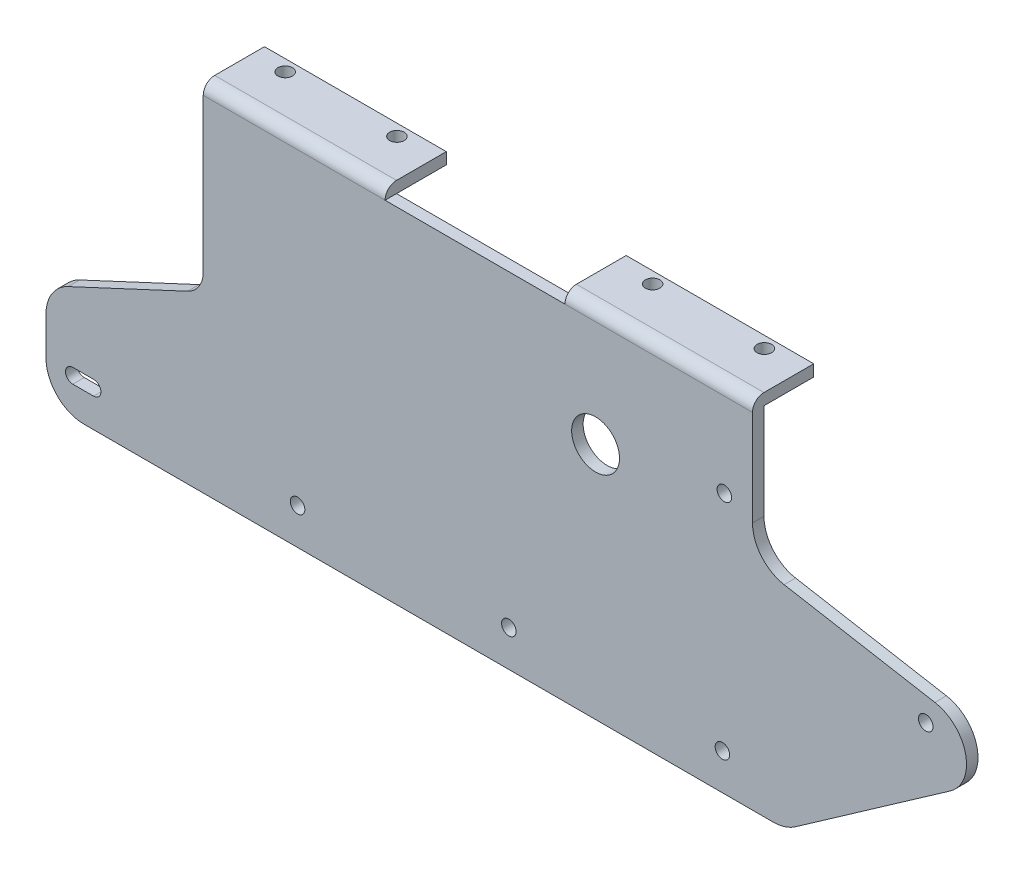
from build123d import *

# Parameters (mm, degrees)
BOSS_EXTRUDE1_DEPTH = 3
SKETCH2_R           = 1.9
SKETCH2_R_2         = 6.25
CUT_EXTRUDE1_DEPTH  = 4
BOSS_EXTRUDE2_DEPTH = 143.5
SKETCH4_W           = 47
SKETCH4_H           = 16
CUT_EXTRUDE2_DEPTH  = 3
SKETCH5_R           = 1.9
CUT_EXTRUDE3_DEPTH  = 94


with BuildPart() as part:
    # Sketch1 → Boss-Extrude1 (new body)
    with BuildSketch(Plane.XY):
        with BuildLine():
            Line((0, 0), (143.5, 0))
            Line((143.5, 0), (143.5, -25))
            ThreePointArc((143.5, -25), (145.839555569, -31.427876097), (151.763518223, -34.84807753))
            Line((151.763518223, -34.84807753), (191.155828344, -41.794004637))
            ThreePointArc((191.155828344, -41.794004637), (199.182306638, -49.477686028), (195.155110931, -59.83360261))
            Line((195.155110931, -59.83360261), (154.655807102, -88.191520443))
            ThreePointArc((154.655807102, -88.191520443), (151.927100734, -89.537169507), (148.920042738, -90))
            Line((148.920042738, -90), (-31.079957262, -90))
            ThreePointArc((-31.079957262, -90), (-38.151025073, -87.071067812), (-41.079957262, -80))
            Line((-41.079957262, -80), (-41.079957262, -70))
            ThreePointArc((-41.079957262, -70), (-39.51387172, -64.627003917), (-35.306139879, -60.93692213))
            Line((-35.306139879, -60.93692213), (-4.054276098, -46.363938717))
            ThreePointArc((-4.054276098, -46.363938717), (-1.099678559, -43.772826218), (0, -40))
            Line((0, -40), (0, 0))
        make_face()
    extrude(amount=BOSS_EXTRUDE1_DEPTH)

    # Sketch2 → Cut-Extrude1 (cut, through all)
    with BuildSketch(Plane.XY.offset(3)):
        with Locations((188.758637025, -47.565112823)):
            Circle(SKETCH2_R)
        with Locations((135.640436691, -80.5)):
            Circle(SKETCH2_R)
        with Locations((79.840436691, -80.5)):
            Circle(SKETCH2_R)
        with Locations((24.640436691, -80.5)):
            Circle(SKETCH2_R)
        with Locations((102.5, -27.75)):
            Circle(SKETCH2_R_2)
        with Locations((136.140436691, -22)):
            Circle(SKETCH2_R)
        with BuildLine():
            Line((-28.634563309, -82.4), (-34.084563309, -82.4))
            ThreePointArc((-34.084563309, -82.4), (-35.984563309, -80.5), (-34.084563309, -78.6))
            Line((-34.084563309, -78.6), (-28.634563309, -78.6))
            ThreePointArc((-28.634563309, -78.6), (-26.734563309, -80.5), (-28.634563309, -82.4))
        make_face()
    extrude(amount=-CUT_EXTRUDE1_DEPTH, mode=Mode.SUBTRACT)

    # Sketch3 → Boss-Extrude2 (add)
    with BuildSketch(Plane(origin=(143.5, 0, 0), x_dir=(0, 0, -1), z_dir=(1, 0, 0))):
        with BuildLine():
            Line((0, 0), (13, 0))
            Line((13, 0), (13, 3))
            Line((13, 3), (0, 3))
            ThreePointArc((0, 3), (-2.121320344, 2.121320344), (-3, 0))
            Line((-3, 0), (0, 0))
        make_face()
    extrude(amount=-BOSS_EXTRUDE2_DEPTH)

    # Sketch4 → Cut-Extrude2 (cut)
    with BuildSketch(Plane(origin=(0, 3, 0), x_dir=(1, 0, 0), z_dir=(0, 1, 0))):
        with Locations((71, 5)):
            Rectangle(SKETCH4_W, SKETCH4_H)
    extrude(amount=-CUT_EXTRUDE2_DEPTH, mode=Mode.SUBTRACT)

    # Sketch5 → Cut-Extrude3 (cut, through all)
    with BuildSketch(Plane(origin=(0, 3, 0), x_dir=(1, 0, 0), z_dir=(0, 1, 0))):
        with Locations((8.4, 10)):
            Circle(SKETCH5_R)
        with Locations((37.6, 10)):
            Circle(SKETCH5_R)
        with Locations((104.4, 10)):
            Circle(SKETCH5_R)
        with Locations((133.6, 10)):
            Circle(SKETCH5_R)
    extrude(amount=-CUT_EXTRUDE3_DEPTH, mode=Mode.SUBTRACT)


solid = part.part
